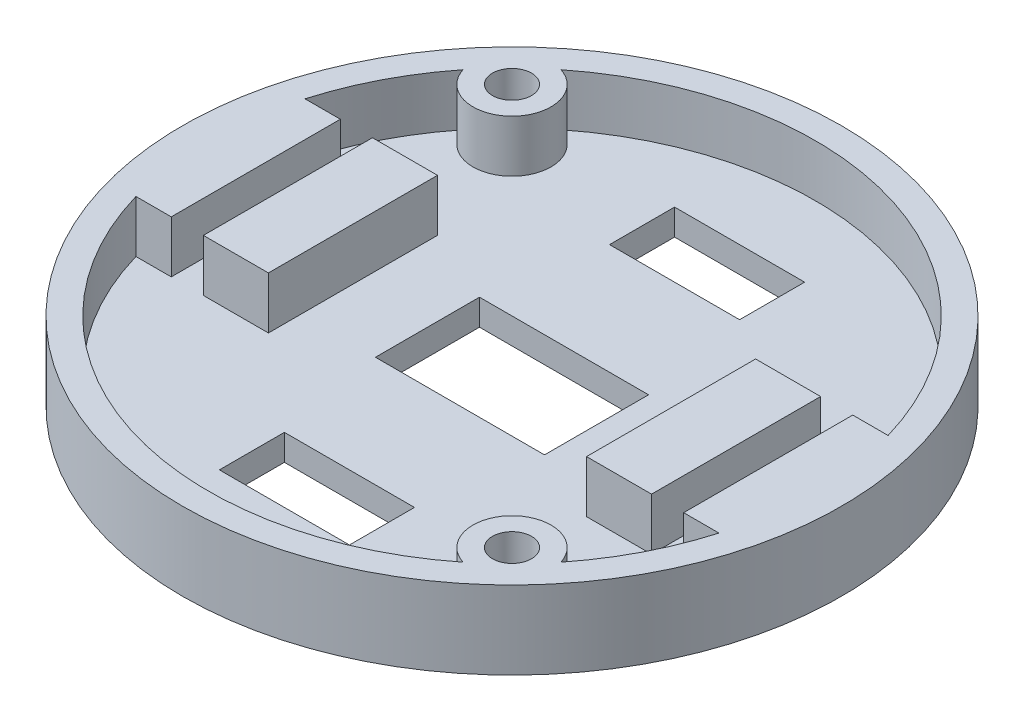
from build123d import *

# Parameters (mm, degrees)
SKETCH1_R           = 25.34
BOSS_EXTRUDE1_DEPTH = 2
SKETCH2_W           = 5
SKETCH2_H           = 13
BOSS_EXTRUDE2_DEPTH = 4
SKETCH3_R           = 1.5
CUT_EXTRUDE1_DEPTH  = 3
SKETCH4_W           = 10
SKETCH4_H           = 5
SKETCH4_W_2         = 13
SKETCH4_H_2         = 8
CUT_EXTRUDE2_DEPTH  = 3
SKETCH7_R           = 25.34
SKETCH7_R_2         = 1.5
BOSS_EXTRUDE3_DEPTH = 4


with BuildPart() as part:
    # Sketch1 → Boss-Extrude1 (new body)
    with BuildSketch(Plane(origin=(0, 0, 0), x_dir=(1, 0, 0), z_dir=(0, 1, 0))):
        Circle(SKETCH1_R)
    extrude(amount=BOSS_EXTRUDE1_DEPTH)

    # Sketch2 → Boss-Extrude2 (add)
    with BuildSketch(Plane(origin=(0, 2, 0), x_dir=(1, 0, 0), z_dir=(0, 1, 0))):
        with Locations((14.73, 0)):
            Rectangle(SKETCH2_W, SKETCH2_H)
        with BuildLine():
            Line((22.416636679, 6.5), (19.7, 6.5))
            Line((19.7, 6.5), (19.7, -6.5))
            Line((19.7, -6.5), (22.416636679, -6.5))
            ThreePointArc((22.416636679, -6.5), (23.34, 0), (22.416636679, 6.5))
        make_face()
        with BuildLine():
            Line((-19.7, -6.5), (-22.416636679, -6.5))
            ThreePointArc((-22.416636679, -6.5), (-23.34, 0), (-22.416636679, 6.5))
            Line((-22.416636679, 6.5), (-19.7, 6.5))
            Line((-19.7, 6.5), (-19.7, -6.5))
        make_face()
        with Locations((-14.73, 0)):
            Rectangle(SKETCH2_W, SKETCH2_H)
    extrude(amount=BOSS_EXTRUDE2_DEPTH)

    # Sketch3 → Cut-Extrude1 (cut, through all)
    with BuildSketch(Plane(origin=(0, 2, 0), x_dir=(1, 0, 0), z_dir=(0, 1, 0))):
        with Locations((-15.421998898, 15.421998898)):
            Circle(SKETCH3_R)
        with Locations((15.421998898, -15.421998898)):
            Circle(SKETCH3_R)
    extrude(amount=-CUT_EXTRUDE1_DEPTH, mode=Mode.SUBTRACT)

    # Sketch4 → Cut-Extrude2 (cut, through all)
    with BuildSketch(Plane(origin=(0, 2, 0), x_dir=(1, 0, 0), z_dir=(0, 1, 0))):
        with Locations((0, 15)):
            Rectangle(SKETCH4_W, SKETCH4_H)
        with Locations((0, -15)):
            Rectangle(SKETCH4_W, SKETCH4_H)
        Rectangle(SKETCH4_W_2, SKETCH4_H_2)
    extrude(amount=-CUT_EXTRUDE2_DEPTH, mode=Mode.SUBTRACT)

    # Sketch7 → Boss-Extrude3 (add)
    with BuildSketch(Plane(origin=(0, 2, 0), x_dir=(1, 0, 0), z_dir=(0, 1, 0))):
        Circle(SKETCH7_R)
        with Locations((-15.421998898, 15.421998898)):
            Circle(SKETCH7_R_2, mode=Mode.SUBTRACT)
        with Locations((15.421998898, -15.421998898)):
            Circle(SKETCH7_R_2, mode=Mode.SUBTRACT)
        with BuildLine():
            ThreePointArc((18.280458496, -14.511389912), (13.300678554, -13.300678554), (14.511389912, -18.280458496))
            ThreePointArc((14.511389912, -18.280458496), (-16.503872273, -16.503872273), (-18.280458496, 14.511389912))
            ThreePointArc((-18.280458496, 14.511389912), (-13.300678554, 13.300678554), (-14.511389912, 18.280458496))
            ThreePointArc((-14.511389912, 18.280458496), (16.503872273, 16.503872273), (18.280458496, -14.511389912))
        make_face(mode=Mode.SUBTRACT)
    extrude(amount=BOSS_EXTRUDE3_DEPTH)


solid = part.part
